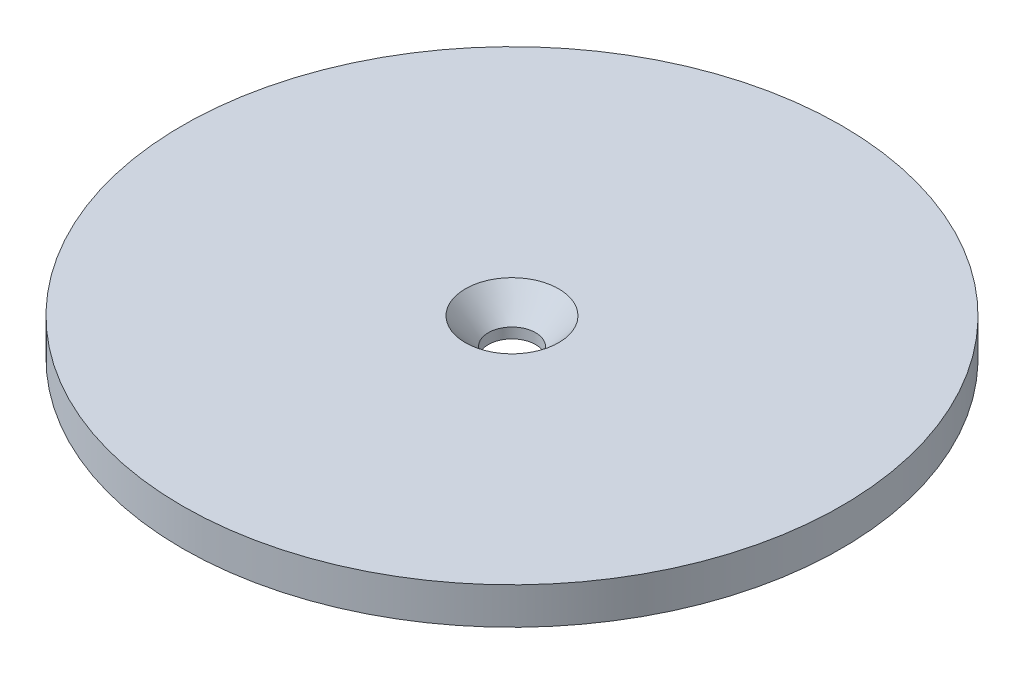
from build123d import *

# Parameters (mm, degrees)
SKETCH1_R                                        = 45.466
BOSS_EXTRUDE1_DEPTH                              = 25.4
SKETCH3_R                                        = 20.32
CUT_EXTRUDE1_DEPTH                               = 12.7
CSK_FOR_1_4_FLAT_HEAD_MACHINE_SCREW1_D           = 6.5278
CSK_FOR_1_4_FLAT_HEAD_MACHINE_SCREW1_DEPTH       = 25.4
CSK_FOR_1_4_FLAT_HEAD_MACHINE_SCREW1_CSINK_D     = 12.8778
CSK_FOR_1_4_FLAT_HEAD_MACHINE_SCREW1_CSINK_ANGLE = 82
CSK_FOR_1_4_FLAT_HEAD_MACHINE_SCREW1_TIP         = 1.961148974
SKETCH9_R                                        = 53.031918303
CUT_EXTRUDE3_DEPTH                               = 20.322357613


with BuildPart() as part:
    # Sketch1 → Boss-Extrude1 (new body)
    with BuildSketch(Plane(origin=(0, 0, 0), x_dir=(1, 0, 0), z_dir=(0, 1, 0))):
        Circle(SKETCH1_R)
    extrude(amount=BOSS_EXTRUDE1_DEPTH)

    # Sketch3 → Cut-Extrude1 (cut)
    with BuildSketch(Plane.XZ):
        Circle(SKETCH3_R)
    extrude(amount=-CUT_EXTRUDE1_DEPTH, mode=Mode.SUBTRACT)

    # CSK for 1/4 Flat Head Machine Screw1
    with Locations(Plane(origin=(0, 25.4, 0), x_dir=(1, 0, 0), z_dir=(0, 1, 0))):
        with Locations((0, 0)):
            CounterSinkHole(CSK_FOR_1_4_FLAT_HEAD_MACHINE_SCREW1_D / 2, CSK_FOR_1_4_FLAT_HEAD_MACHINE_SCREW1_CSINK_D / 2, depth=CSK_FOR_1_4_FLAT_HEAD_MACHINE_SCREW1_DEPTH, counter_sink_angle=CSK_FOR_1_4_FLAT_HEAD_MACHINE_SCREW1_CSINK_ANGLE)
            with Locations((0, 0, -(CSK_FOR_1_4_FLAT_HEAD_MACHINE_SCREW1_DEPTH + CSK_FOR_1_4_FLAT_HEAD_MACHINE_SCREW1_TIP / 2))):  # 118° drill point
                Cone(0, CSK_FOR_1_4_FLAT_HEAD_MACHINE_SCREW1_D / 2, CSK_FOR_1_4_FLAT_HEAD_MACHINE_SCREW1_TIP, mode=Mode.SUBTRACT)

    # Sketch9 → Cut-Extrude3 (cut)
    with BuildSketch(Plane.XZ):
        Circle(SKETCH9_R)
    extrude(amount=-CUT_EXTRUDE3_DEPTH, mode=Mode.SUBTRACT)


solid = part.part
